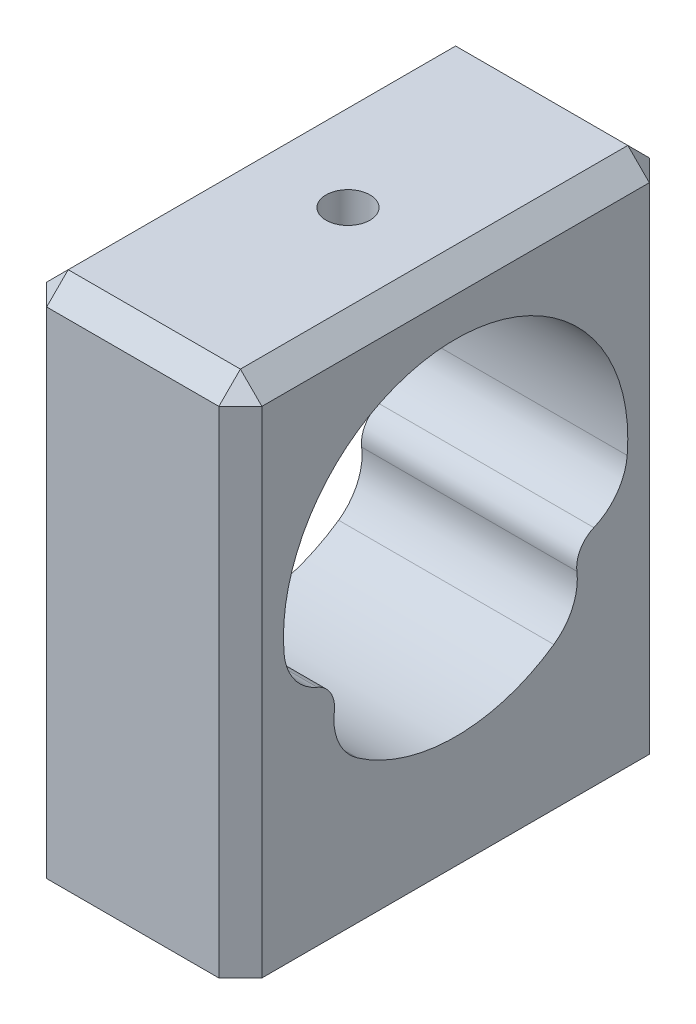
from build123d import *

# Parameters (mm, degrees)
SKETCH1_W                       = 50
SKETCH1_H                       = 60
SKETCH1_R                       = 20
BOSS_EXTRUDE1_DEPTH             = 25
CHAMFER1_SIZE                   = 2.5
F_1_4_20_TAPPED_HOLE1_REACH     = 68.191
F_1_4_20_TAPPED_HOLE1_BORE_R    = 2.5527
F_1_4_0_25_DIAMETER_HOLE1_D     = 6.35
F_1_4_0_25_DIAMETER_HOLE1_DEPTH = 10
F_1_4_0_25_DIAMETER_HOLE1_TIP   = 1.907732465


with BuildPart() as part:
    # Sketch1 → Boss-Extrude1 (new body)
    with BuildSketch(Plane(origin=(0, 0, 0), x_dir=(0, 0, -1), z_dir=(1, 0, 0))):
        with Locations((-0.046631749, 12.797960187)):
            Rectangle(SKETCH1_W, SKETCH1_H)
        with Locations((-0.046631749, 15.817960187)):
            Circle(SKETCH1_R, mode=Mode.SUBTRACT)
        with BuildLine():
            ThreePointArc((15.41920449, 3.136954335), (17.273876327, 5.817960187), (18.668359584, 8.764656039))
            ThreePointArc((18.668359584, 8.764656039), (17.346806711, 9.077144311), (16.012598617, 8.824083694))
            ThreePointArc((16.012598617, 8.824083694), (15.118822775, 8.264047714), (14.450633556, 7.447960267))
            ThreePointArc((14.450633556, 7.447960267), (14.077975631, 6.461247636), (14.039858148, 5.407196971))
            ThreePointArc((14.039858148, 5.407196971), (14.487805271, 4.125208558), (15.41920449, 3.136954335))
        make_face()
        with BuildLine():
            ThreePointArc((-16.105862115, 8.824083694), (-17.440070209, 9.077144311), (-18.761623082, 8.764656039))
            ThreePointArc((-18.761623082, 8.764656039), (-17.367139825, 5.817960187), (-15.512467988, 3.136954335))
            ThreePointArc((-15.512467988, 3.136954335), (-14.581068769, 4.125208558), (-14.133121646, 5.407196971))
            ThreePointArc((-14.133121646, 5.407196971), (-14.17123911, 6.461247542), (-14.543896959, 7.447960101))
            ThreePointArc((-14.543896959, 7.447960101), (-15.212086202, 8.264047651), (-16.105862115, 8.824083694))
        make_face()
        with BuildLine():
            ThreePointArc((18.668359584, 8.764656039), (19.462739812, 11.415185915), (19.883693667, 14.149988727))
            ThreePointArc((19.883693667, 14.149988727), (18.69234004, 10.946124329), (16.012598617, 8.824083694))
            ThreePointArc((16.012598617, 8.824083694), (17.346806711, 9.077144311), (18.668359584, 8.764656039))
        make_face()
        with BuildLine():
            ThreePointArc((11.363036616, -0.6082222), (13.520968398, 1.123735939), (15.41920449, 3.136954335))
            ThreePointArc((15.41920449, 3.136954335), (14.487805271, 4.125208558), (14.039858148, 5.407196971))
            ThreePointArc((14.039858148, 5.407196971), (13.541987762, 2.025452506), (11.363036616, -0.6082222))
        make_face()
        with BuildLine():
            ThreePointArc((-16.105862115, 8.824083694), (-18.785603538, 10.946124329), (-19.976957166, 14.149988727))
            ThreePointArc((-19.976957166, 14.149988727), (-19.55600331, 11.415185915), (-18.761623082, 8.764656039))
            ThreePointArc((-18.761623082, 8.764656039), (-17.440070209, 9.077144311), (-16.105862115, 8.824083694))
        make_face()
        with BuildLine():
            ThreePointArc((-14.133121646, 5.407196971), (-14.581068769, 4.125208558), (-15.512467988, 3.136954335))
            ThreePointArc((-15.512467988, 3.136954335), (-13.614231896, 1.123735939), (-11.456300114, -0.6082222))
            ThreePointArc((-11.456300114, -0.6082222), (-13.63525126, 2.025452506), (-14.133121646, 5.407196971))
        make_face()
    extrude(amount=BOSS_EXTRUDE1_DEPTH)

    # Chamfer1
    chamfer1_edges = [part.edges().sort_by_distance(p)[0] for p in [
        (0, 12.797960187, -24.953368251),
        (0, 12.797960187, 25.046631749),
        (0, 42.797960187, 0.046631749),
        (12.5, 42.797960187, -24.953368251),
        (12.5, 42.797960187, 25.046631749),
        (25, 42.797960187, 0.046631749),
        (25, 12.797960187, 25.046631749),
        (25, 12.797960187, -24.953368251),
    ]]
    chamfer(chamfer1_edges, length=CHAMFER1_SIZE)

    # 1/4-20 Tapped Hole1 bore (on position points) → 1/4-20 Tapped Hole1 (cut, up to next)
    with BuildSketch(Plane(origin=(12.5, 42.797960187, 0.046631749), x_dir=(0, 0, 1), z_dir=(0, 1, 0)), mode=Mode.PRIVATE) as f_1_4_20_tapped_hole1_sk1:
        Circle(F_1_4_20_TAPPED_HOLE1_BORE_R)
    f_1_4_20_tapped_hole1_tool1 = extrude(f_1_4_20_tapped_hole1_sk1.sketch, amount=-F_1_4_20_TAPPED_HOLE1_REACH, mode=Mode.PRIVATE) & part.part
    add(f_1_4_20_tapped_hole1_tool1.solids().sort_by_distance((12.5, 42.79796, 0.046632))[0], mode=Mode.SUBTRACT)

    # 1/4 (0.25) Diameter Hole1
    with Locations(Plane(origin=(12.5, -17.202039813, 15.046631749), x_dir=(0, 0, -1), z_dir=(0, -1, 0))):
        with Locations((0, 0), (30, 0)):
            Hole(F_1_4_0_25_DIAMETER_HOLE1_D / 2, depth=F_1_4_0_25_DIAMETER_HOLE1_DEPTH)
            with Locations((0, 0, -(F_1_4_0_25_DIAMETER_HOLE1_DEPTH + F_1_4_0_25_DIAMETER_HOLE1_TIP / 2))):  # 118° drill point
                Cone(0, F_1_4_0_25_DIAMETER_HOLE1_D / 2, F_1_4_0_25_DIAMETER_HOLE1_TIP, mode=Mode.SUBTRACT)


solid = part.part
